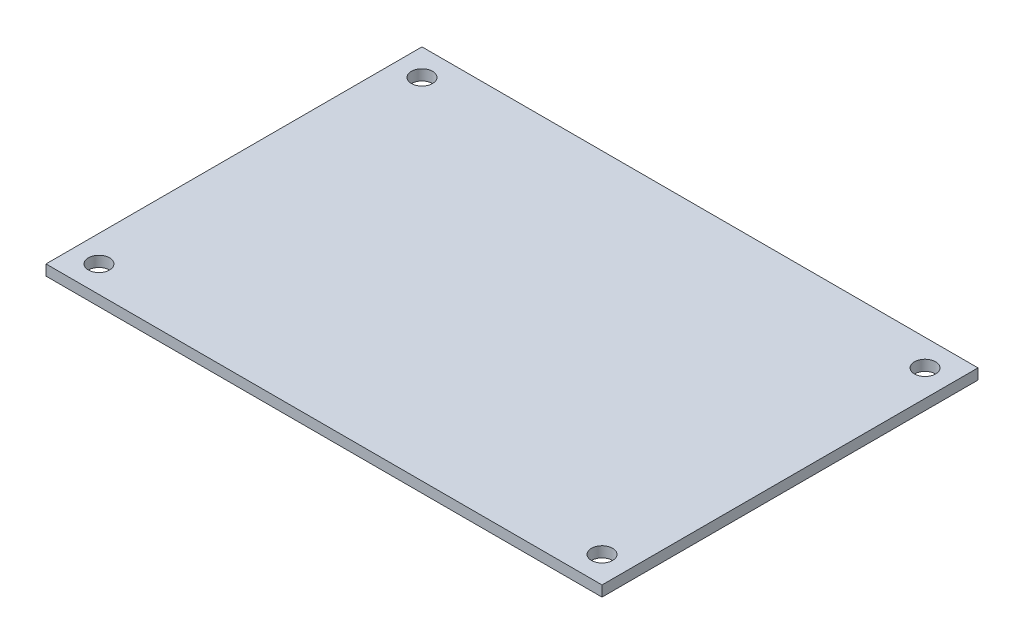
from build123d import *

# Parameters (mm, degrees)
SKETCH1_W           = 105
SKETCH1_H           = 71
SKETCH1_R           = 2
BOSS_EXTRUDE1_DEPTH = 2


with BuildPart() as part:
    # Sketch1 → Boss-Extrude1 (new body)
    with BuildSketch(Plane(origin=(0, 0, 0), x_dir=(1, 0, 0), z_dir=(0, 1, 0))):
        Rectangle(SKETCH1_W, SKETCH1_H)
        with Locations((-47.5, 30.5)):
            Circle(SKETCH1_R, mode=Mode.SUBTRACT)
        with Locations((47.5, 30.5)):
            Circle(SKETCH1_R, mode=Mode.SUBTRACT)
        with Locations((47.5, -30.5)):
            Circle(SKETCH1_R, mode=Mode.SUBTRACT)
        with Locations((-47.5, -30.5)):
            Circle(SKETCH1_R, mode=Mode.SUBTRACT)
    extrude(amount=BOSS_EXTRUDE1_DEPTH)


solid = part.part
